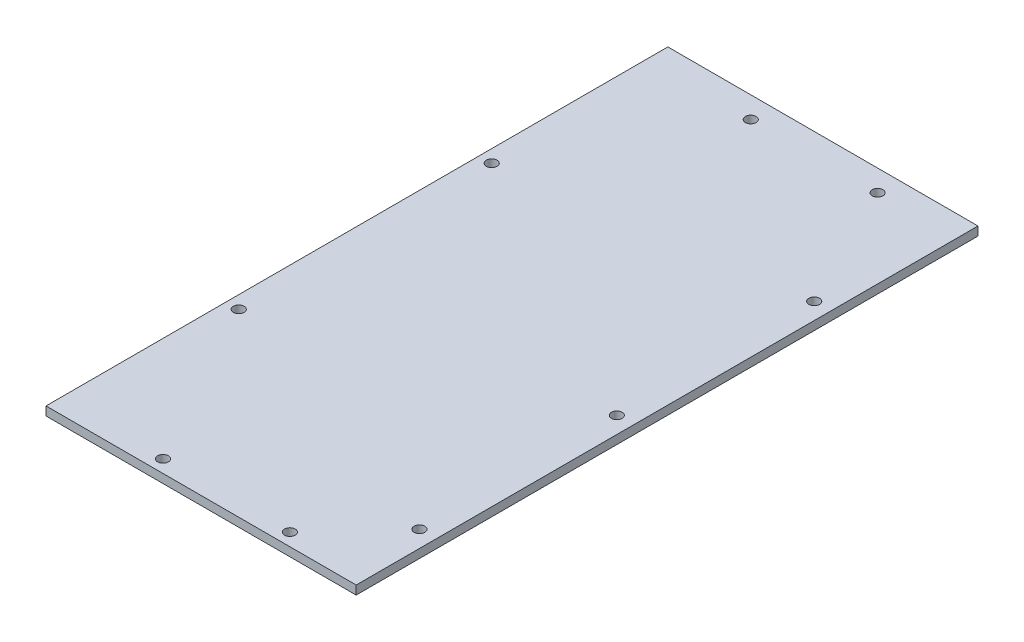
from build123d import *

# Parameters (mm, degrees)
SKETCH1_W             = 110
SKETCH1_H             = 220.5325
BOSS_EXTRUDE1_DEPTH   = 3.1
F_6_CLEARANCE_HOLE1_D = 3.7973
F_6_CLEARANCE_HOLE3_D = 3.7973


with BuildPart() as part:
    # Sketch1 → Boss-Extrude1 (new body)
    with BuildSketch(Plane(origin=(0, 0, 0), x_dir=(1, 0, 0), z_dir=(0, 1, 0))):
        Rectangle(SKETCH1_W, SKETCH1_H)
    extrude(amount=BOSS_EXTRUDE1_DEPTH)

    # #6 Clearance Hole1 (through all)
    with Locations(Plane(origin=(0, 3.1, 0), x_dir=(1, 0, 0), z_dir=(0, 1, 0))):
        with Locations((49.1, 58.075), (49.1, -11.925), (49.1, -81.925), (-50.4997, -46.411275), (-50.4997, 43.307075)):
            Hole(F_6_CLEARANCE_HOLE1_D / 2)

    # #6 Clearance Hole3 (through all)
    with Locations(Plane(origin=(0, 0, 0), x_dir=(-1, 0, 0), z_dir=(0, -1, 0))):
        with Locations((-27.0003, 102.66625), (17.9997, 102.66625), (-27.0003, -105.77045), (17.9997, -105.77045)):
            Hole(F_6_CLEARANCE_HOLE3_D / 2)


solid = part.part
